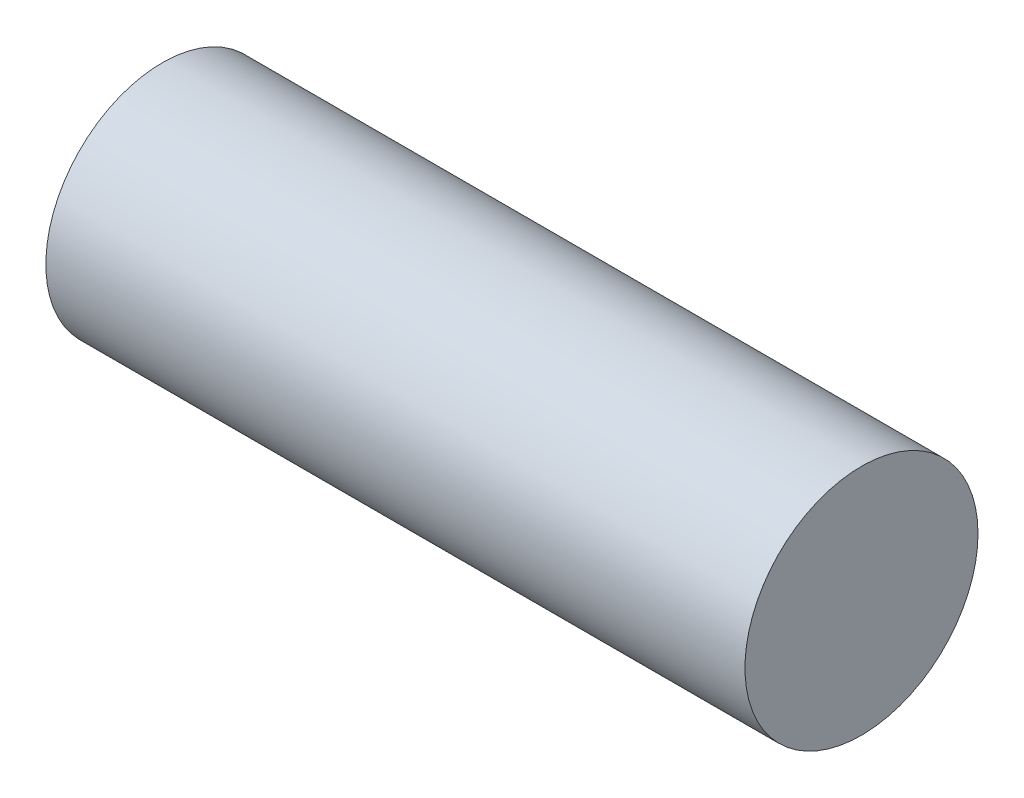
from build123d import *

# Parameters (mm, degrees)
ESQUISSE1_R        = 5
BOSS_EXTRU_1_DEPTH = 15


with BuildPart() as part:
    # Esquisse1 → Boss.-Extru.1 (new body, symmetric)
    with BuildSketch(Plane(origin=(0, 0, 0), x_dir=(0, 0, -1), z_dir=(1, 0, 0))):
        Circle(ESQUISSE1_R)
    extrude(amount=BOSS_EXTRU_1_DEPTH, both=True)


solid = part.part
